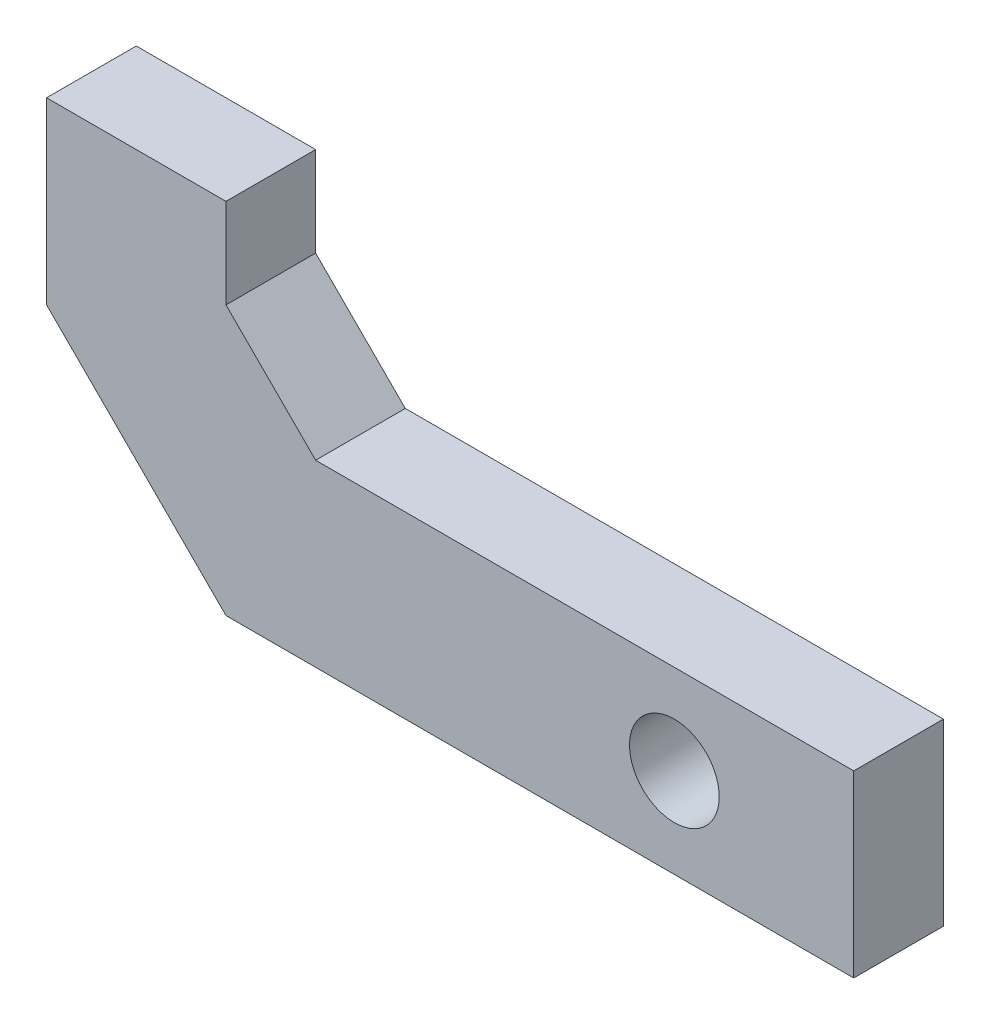
from build123d import *

# Parameters (mm, degrees)
BOSS_EXTRUDE1_DEPTH = 2.54
CUT_EXTRUDE1_REACH  = 4.54
SKETCH2_R           = 1.27


with BuildPart() as part:
    # Sketch1 → Boss-Extrude1 (new body)
    with BuildSketch(Plane.XY):
        Polygon((0, 0), (-5.08, 5.08), (-5.08, 10.16), (0, 10.16), (0, 7.62), (2.54, 5.08), (17.78, 5.08), (17.78, 0), align=None)
    extrude(amount=BOSS_EXTRUDE1_DEPTH)

    # Sketch2 → Cut-Extrude1 (cut, up to next)
    with BuildSketch(Plane.XY.offset(2.54), mode=Mode.PRIVATE) as cut_extrude1_sk1:
        with Locations((12.7, 2.54)):
            Circle(SKETCH2_R)
    cut_extrude1_tool1 = extrude(cut_extrude1_sk1.sketch, amount=-CUT_EXTRUDE1_REACH, mode=Mode.PRIVATE) & part.part
    add(cut_extrude1_tool1.solids().sort_by_distance((12.7, 2.54, 2.54))[0], mode=Mode.SUBTRACT)


solid = part.part
